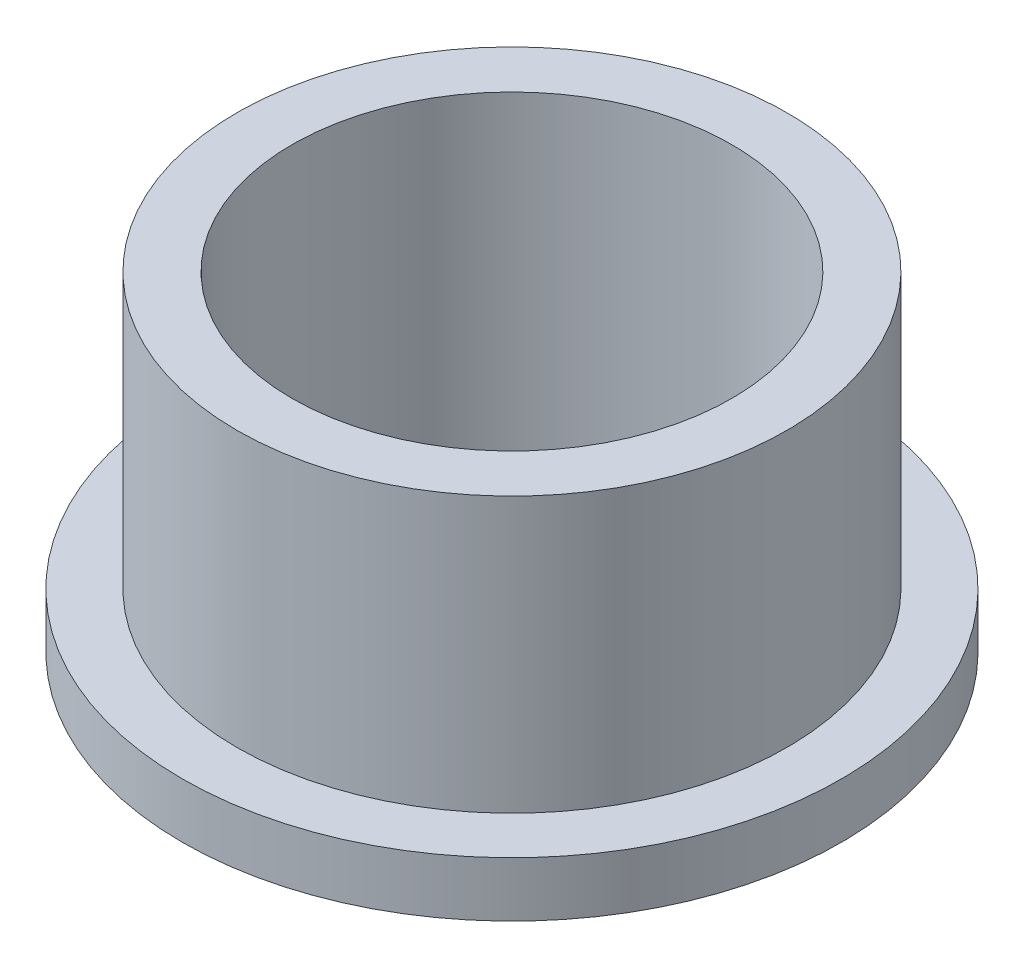
from build123d import *

# Parameters (mm, degrees)
SKETCH2_R           = 15.9004
SKETCH2_R_2         = 12.71016
BOSS_EXTRUDE1_DEPTH = 19.05
SKETCH3_R           = 19.05
SKETCH3_R_2         = 15.9004
BOSS_EXTRUDE2_DEPTH = 3.175


with BuildPart() as part:
    # Sketch2 → Boss-Extrude1 (new body)
    with BuildSketch(Plane(origin=(0, 0, 0), x_dir=(1, 0, 0), z_dir=(0, 1, 0))):
        Circle(SKETCH2_R)
        Circle(SKETCH2_R_2, mode=Mode.SUBTRACT)
    extrude(amount=BOSS_EXTRUDE1_DEPTH)

    # Sketch3 → Boss-Extrude2 (add)
    with BuildSketch(Plane(origin=(0, 0, 0), x_dir=(1, 0, 0), z_dir=(0, 1, 0))):
        Circle(SKETCH3_R)
        Circle(SKETCH3_R_2, mode=Mode.SUBTRACT)
    extrude(amount=BOSS_EXTRUDE2_DEPTH)


solid = part.part
